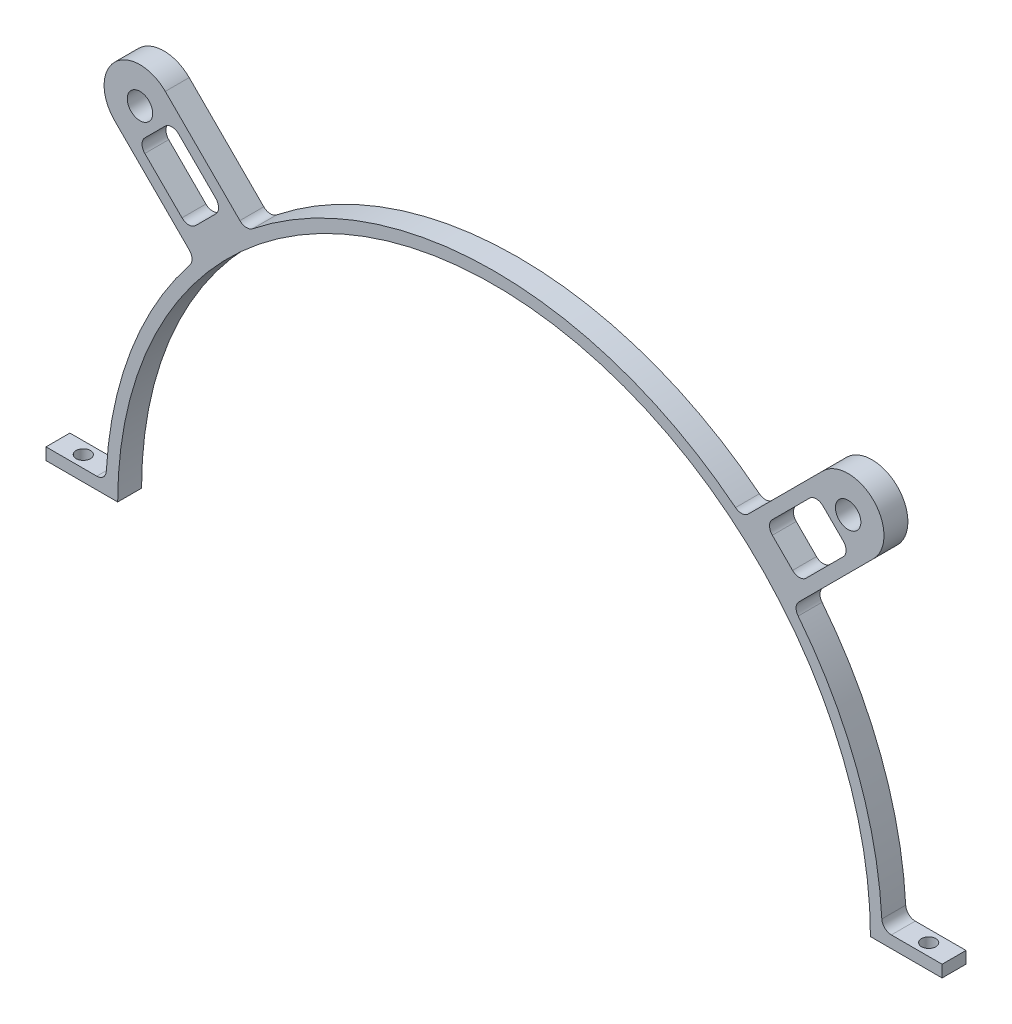
from build123d import *

# Parameters (mm, degrees)
BOSS_EXTRUDE1_DEPTH  = 6.35
FILLET1_R            = 2.54
BOSS_EXTRUDE2_DEPTH  = 6.35
FILLET2_R            = 2.54
FILLET2_OF_MIRROR1_R = 2.54


with BuildPart() as part:
    # Sketch1 → Boss-Extrude1 (new body)
    with BuildSketch(Plane.XY):
        with BuildLine():
            Line((-100.0379, 0), (-119.0879, 0))
            Line((-119.0879, 0), (-119.0879, 3.175))
            Line((-119.0879, 3.175), (-103.164054309, 3.175))
            ThreePointArc((-103.164054309, 3.175), (0, 103.2129), (103.164054309, 3.175))
            Line((103.164054309, 3.175), (119.0879, 3.175))
            Line((119.0879, 3.175), (119.0879, 0))
            Line((119.0879, 0), (100.0379, 0))
            ThreePointArc((100.0379, 0), (0, 100.0379), (-100.0379, 0))
        make_face()
    extrude(amount=BOSS_EXTRUDE1_DEPTH)

    # Fillet1
    fillet1_edges = [part.edges().sort_by_distance(p)[0] for p in [
        (-103.164054309, 3.175, 3.175),
        (103.164054309, 3.175, 3.175),
    ]]
    fillet(fillet1_edges, radius=FILLET1_R)

    # Sketch2 → Boss-Extrude2 (add)
    with BuildSketch(Plane.XY.offset(6.35)):
        with BuildLine():
            Line((-100.84827624, 87.377892058), (-79.406290546, 65.935906365))
            Line((-79.406290546, 65.935906365), (-70.737477466, 70.737477466))
            Line((-70.737477466, 70.737477466), (-65.935906365, 79.406290546))
            Line((-65.935906365, 79.406290546), (-87.377892058, 100.84827624))
            ThreePointArc((-87.377892058, 100.84827624), (-100.84827624, 100.84827624), (-100.84827624, 87.377892058))
        make_face()
        Polygon((-94.617411453, 85.637155332), (-85.637155332, 94.617411453), (-72.166771151, 81.147027272), (-81.147027272, 72.166771151), align=None, mode=Mode.SUBTRACT)
    boss_extrude2 = extrude(amount=-BOSS_EXTRUDE2_DEPTH)

    # Fillet2
    fillet2_edges = [part.edges().sort_by_distance(p)[0] for p in [
        (-65.935906365, 79.406290546, 3.175),
        (-79.406290546, 65.935906365, 3.175),
        (-94.617411453, 85.637155332, 3.175),
        (-85.637155332, 94.617411453, 3.175),
        (-72.166771151, 81.147027272, 3.175),
        (-81.147027272, 72.166771151, 3.175),
    ]]
    fillet(fillet2_edges, radius=FILLET2_R)

    # Sketch3 → 1/4 Clearance Hole1 (revolve, cut)
    with BuildSketch(Plane(origin=(-94.113084149, 94.113084149, 6.35), x_dir=(0, -1, 0), z_dir=(1, 0, 0))):
        Polygon((0, 0), (0, 27.429827343), (3.3782, 25.4), (3.3782, 0), align=None)
    f_1_4_clearance_hole1 = revolve(axis=Axis((-94.113084149, 94.113084149, 12.7), (0, 0, -1)), mode=Mode.SUBTRACT)

    # Sketch5 → #6 Clearance Hole1 (revolve, cut)
    with BuildSketch(Plane(origin=(-112.343132364, 3.175, 3.175), x_dir=(0, 0, 1), z_dir=(1, 0, 0))):
        Polygon((0, 0), (0, 26.540824014), (1.89865, 25.4), (1.89865, 0), align=None)
    f_6_clearance_hole1 = revolve(axis=Axis((-112.343132364, 9.525, 3.175), (0, -1, 0)), mode=Mode.SUBTRACT)

    # Mirror1: Boss-Extrude2, 1/4 Clearance Hole1, #6 Clearance Hole1 across plane
    add(boss_extrude2.mirror(Plane(origin=(0, 0, 0), x_dir=(0, 0, 1), z_dir=(1, 0, 0))))
    add(f_1_4_clearance_hole1.mirror(Plane(origin=(0, 0, 0), x_dir=(0, 0, 1), z_dir=(1, 0, 0))), mode=Mode.SUBTRACT)
    add(f_6_clearance_hole1.mirror(Plane(origin=(0, 0, 0), x_dir=(0, 0, 1), z_dir=(1, 0, 0))), mode=Mode.SUBTRACT)

    # Fillet2 of Mirror1
    fillet2_of_mirror1_edges = [part.edges().sort_by_distance(p)[0] for p in [
        (65.935906365, 79.406290546, 3.175),
        (79.406290546, 65.935906365, 3.175),
        (94.617411453, 85.637155332, 3.175),
        (85.637155332, 94.617411453, 3.175),
        (72.166771151, 81.147027272, 3.175),
        (81.147027272, 72.166771151, 3.175),
    ]]
    fillet(fillet2_of_mirror1_edges, radius=FILLET2_OF_MIRROR1_R)


solid = part.part
